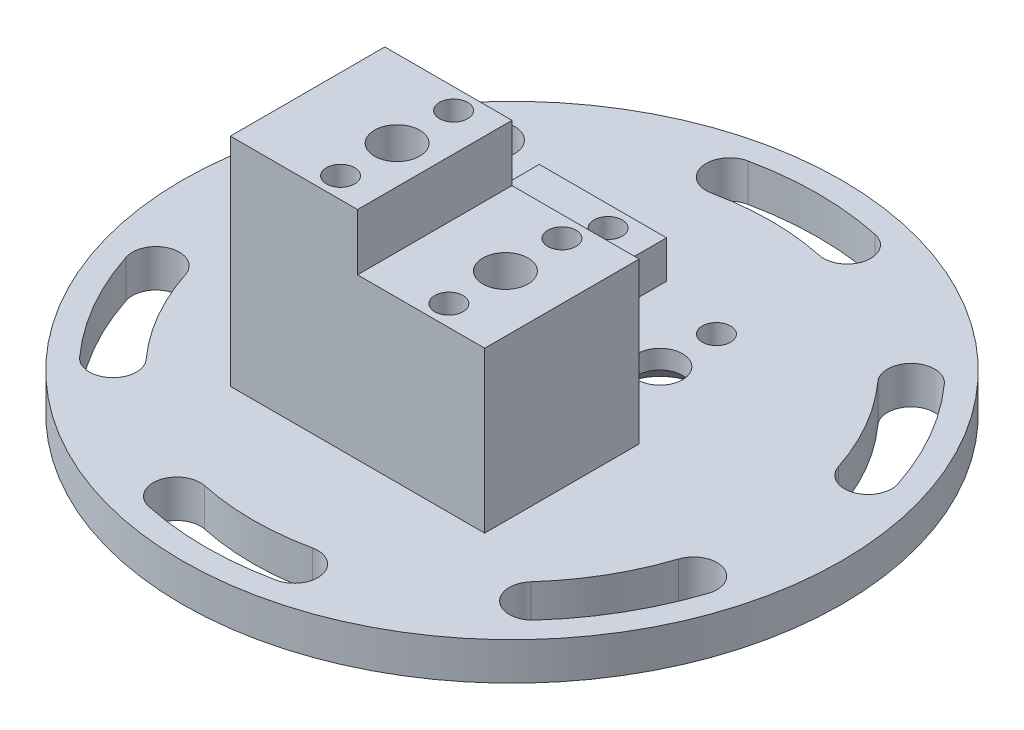
from build123d import *

# Parameters (mm, degrees)
SKETCH1_R                                       = 17.5
BOSS_EXTRUDE1_DEPTH                             = 2
CUT_EXTRUDE1_DEPTH                              = 3
CIRPATTERN1_COUNT                               = 6
SKETCH3_W                                       = 13.5
SKETCH3_H                                       = 16.4
BOSS_EXTRUDE2_DEPTH                             = 17.5
SKETCH4_W                                       = 13.5
SKETCH4_H                                       = 8.2
CUT_EXTRUDE2_DEPTH                              = 11.5
CUT_EXTRUDE3_DEPTH                              = 26.7
CUT_EXTRUDE4_DEPTH                              = 8.2
F_1_5MM_DOWEL_HOLE1_D                           = 1.5
F_1_5MM_DOWEL_HOLE1_DEPTH                       = 5
F_1_5MM_DOWEL_HOLE1_TIP                         = 0.450645464
F_1_5MM_DOWEL_HOLE2_D                           = 1.5
F_1_5MM_DOWEL_HOLE2_DEPTH                       = 3
F_1_5MM_DOWEL_HOLE2_TIP                         = 0.450645464
F_1_5MM_DOWEL_HOLE4_D                           = 1.5
F_1_5MM_DOWEL_HOLE4_DEPTH                       = 5
F_1_5MM_DOWEL_HOLE4_TIP                         = 0.450645464
F_1_5MM_DOWEL_HOLE3_D                           = 1.5
F_1_5MM_DOWEL_HOLE3_DEPTH                       = 5
F_1_5MM_DOWEL_HOLE3_TIP                         = 0.450645464
SKETCH16_R                                      = 1
CUT_EXTRUDE7_DEPTH                              = 14.5
CSK_FOR_M2_FLAT_HEAD_MACHINE_SCREW2_D           = 2.4
CSK_FOR_M2_FLAT_HEAD_MACHINE_SCREW2_CSINK_D     = 4.4
CSK_FOR_M2_FLAT_HEAD_MACHINE_SCREW2_CSINK_ANGLE = 90
CUT_EXTRUDE6_DEPTH                              = 11.5


with BuildPart() as part:
    # Sketch1 → Boss-Extrude1 (new body)
    with BuildSketch(Plane(origin=(0, 0, 0), x_dir=(1, 0, 0), z_dir=(0, 1, 0))):
        Circle(SKETCH1_R)
    extrude(amount=BOSS_EXTRUDE1_DEPTH)

    # Sketch2 → Cut-Extrude1 (cut, through all)
    with BuildSketch(Plane(origin=(0, 2, 0), x_dir=(1, 0, 0), z_dir=(0, 1, 0))):
        with BuildLine():
            ThreePointArc((3.378564976, 15.894898512), (0, 16.25), (-3.378564976, 15.894898512))
            ThreePointArc((-3.378564976, 15.894898512), (-4.341359863, 14.412324397), (-2.858785749, 13.44952951))
            ThreePointArc((-2.858785749, 13.44952951), (0, 13.75), (2.858785749, 13.44952951))
            ThreePointArc((2.858785749, 13.44952951), (4.341359863, 14.412324397), (3.378564976, 15.894898512))
        make_face()
    cut_extrude1 = extrude(amount=-CUT_EXTRUDE1_DEPTH, mode=Mode.SUBTRACT)

    # CirPattern1: Cut-Extrude1 ×6 about axis
    cirpattern1_axis = Axis((0, 0, 0), (0, 1, 0))
    for i in range(1, CIRPATTERN1_COUNT):
        add(cut_extrude1.rotate(cirpattern1_axis, i * 360 / CIRPATTERN1_COUNT), mode=Mode.SUBTRACT)

    # Sketch3 → Boss-Extrude2 (add)
    with BuildSketch(Plane(origin=(0, 2, 0), x_dir=(1, 0, 0), z_dir=(0, 1, 0))):
        Rectangle(SKETCH3_W, SKETCH3_H)
    extrude(amount=BOSS_EXTRUDE2_DEPTH)

    # Sketch4 → Cut-Extrude2 (cut)
    with BuildSketch(Plane(origin=(0, 19.5, 0), x_dir=(1, 0, 0), z_dir=(0, 1, 0))):
        with Locations((0, 4.1)):
            Rectangle(SKETCH4_W, SKETCH4_H)
    extrude(amount=-CUT_EXTRUDE2_DEPTH, mode=Mode.SUBTRACT)

    # Sketch5 → Cut-Extrude3 (cut, through all)
    with BuildSketch(Plane.XY.offset(8.2)):
        Polygon((-6.75, 19.5), (-6.75, 13.5), (0, 13.5), (0, 10.5), (6.75, 10.5), (6.75, 19.5), align=None)
    extrude(amount=-CUT_EXTRUDE3_DEPTH, mode=Mode.SUBTRACT)

    # Sketch6 → Cut-Extrude4 (cut)
    with BuildSketch(Plane(origin=(0, 0, -8.2), x_dir=(-1, 0, 0), z_dir=(0, 0, -1))):
        Polygon((6.75, 8), (6.75, 4), (0, 4), (0, 2), (-6.75, 2), (-6.75, 8), align=None)
    extrude(amount=-CUT_EXTRUDE4_DEPTH, mode=Mode.SUBTRACT)

    # Ø1.5mm Dowel Hole1
    with Locations(Plane(origin=(0, 13.5, 0), x_dir=(1, 0, 0), z_dir=(0, 1, 0))):
        with Locations((-2, -1.1), (-2, -7.1)):
            Hole(F_1_5MM_DOWEL_HOLE1_D / 2, depth=F_1_5MM_DOWEL_HOLE1_DEPTH)
            with Locations((0, 0, -(F_1_5MM_DOWEL_HOLE1_DEPTH + F_1_5MM_DOWEL_HOLE1_TIP / 2))):  # 118° drill point
                Cone(0, F_1_5MM_DOWEL_HOLE1_D / 2, F_1_5MM_DOWEL_HOLE1_TIP, mode=Mode.SUBTRACT)

    # Ø1.5mm Dowel Hole2
    with Locations(Plane(origin=(0, 10.5, 0), x_dir=(1, 0, 0), z_dir=(0, 1, 0))):
        with Locations((3.75, -1.1), (3.75, -7.1)):
            Hole(F_1_5MM_DOWEL_HOLE2_D / 2, depth=F_1_5MM_DOWEL_HOLE2_DEPTH)
            with Locations((0, 0, -(F_1_5MM_DOWEL_HOLE2_DEPTH + F_1_5MM_DOWEL_HOLE2_TIP / 2))):  # 118° drill point
                Cone(0, F_1_5MM_DOWEL_HOLE2_D / 2, F_1_5MM_DOWEL_HOLE2_TIP, mode=Mode.SUBTRACT)

    # Ø1.5mm Dowel Hole4
    with Locations(Plane(origin=(0, 4, 0), x_dir=(1, 0, 0), z_dir=(0, 1, 0))):
        with Locations((-2, 7.1), (-2, 1.1)):
            Hole(F_1_5MM_DOWEL_HOLE4_D / 2, depth=F_1_5MM_DOWEL_HOLE4_DEPTH)
            with Locations((0, 0, -(F_1_5MM_DOWEL_HOLE4_DEPTH + F_1_5MM_DOWEL_HOLE4_TIP / 2))):  # 118° drill point
                Cone(0, F_1_5MM_DOWEL_HOLE4_D / 2, F_1_5MM_DOWEL_HOLE4_TIP, mode=Mode.SUBTRACT)

    # Ø1.5mm Dowel Hole3
    with Locations(Plane(origin=(0, 2, 0), x_dir=(1, 0, 0), z_dir=(0, 1, 0))):
        with Locations((3.75, 7.1), (3.75, 1.1)):
            Hole(F_1_5MM_DOWEL_HOLE3_D / 2, depth=F_1_5MM_DOWEL_HOLE3_DEPTH)
            with Locations((0, 0, -(F_1_5MM_DOWEL_HOLE3_DEPTH + F_1_5MM_DOWEL_HOLE3_TIP / 2))):  # 118° drill point
                Cone(0, F_1_5MM_DOWEL_HOLE3_D / 2, F_1_5MM_DOWEL_HOLE3_TIP, mode=Mode.SUBTRACT)

    # Sketch16 → Cut-Extrude7 (cut, through all)
    with BuildSketch(Plane(origin=(0, 13.5, 0), x_dir=(1, 0, 0), z_dir=(0, 1, 0))):
        with Locations((-2, -4.1)):
            Circle(SKETCH16_R)
        with Locations((3.75, -4.1)):
            Circle(SKETCH16_R)
        with Locations((3.75, 4.1)):
            Circle(SKETCH16_R)
        with Locations((-2, 4.1)):
            Circle(SKETCH16_R)
    extrude(amount=-CUT_EXTRUDE7_DEPTH, mode=Mode.SUBTRACT)

    # CSK for M2 Flat Head Machine Screw2 (through all)
    with Locations(Plane(origin=(0, 0, 0), x_dir=(-1, 0, 0), z_dir=(0, -1, 0))):
        with Locations((-3.75, 4.1), (2, 4.1), (2, -4.1), (-3.75, -4.1)):
            CounterSinkHole(CSK_FOR_M2_FLAT_HEAD_MACHINE_SCREW2_D / 2, CSK_FOR_M2_FLAT_HEAD_MACHINE_SCREW2_CSINK_D / 2, counter_sink_angle=CSK_FOR_M2_FLAT_HEAD_MACHINE_SCREW2_CSINK_ANGLE)

    # Sketch19 → Cut-Extrude6 (cut)
    with BuildSketch(Plane(origin=(0, 2, 0), x_dir=(1, 0, 0), z_dir=(0, 1, 0))):
        with BuildLine():
            Line((-0.25, 1.5), (1.22977385, 1.5))
            ThreePointArc((1.22977385, 1.5), (1.97977385, 0.75), (1.22977385, 0))
            Line((1.22977385, 0), (-0.25, 0))
            ThreePointArc((-0.25, 0), (-1, 0.75), (-0.25, 1.5))
        make_face()
    extrude(amount=CUT_EXTRUDE6_DEPTH, mode=Mode.SUBTRACT)


solid = part.part
